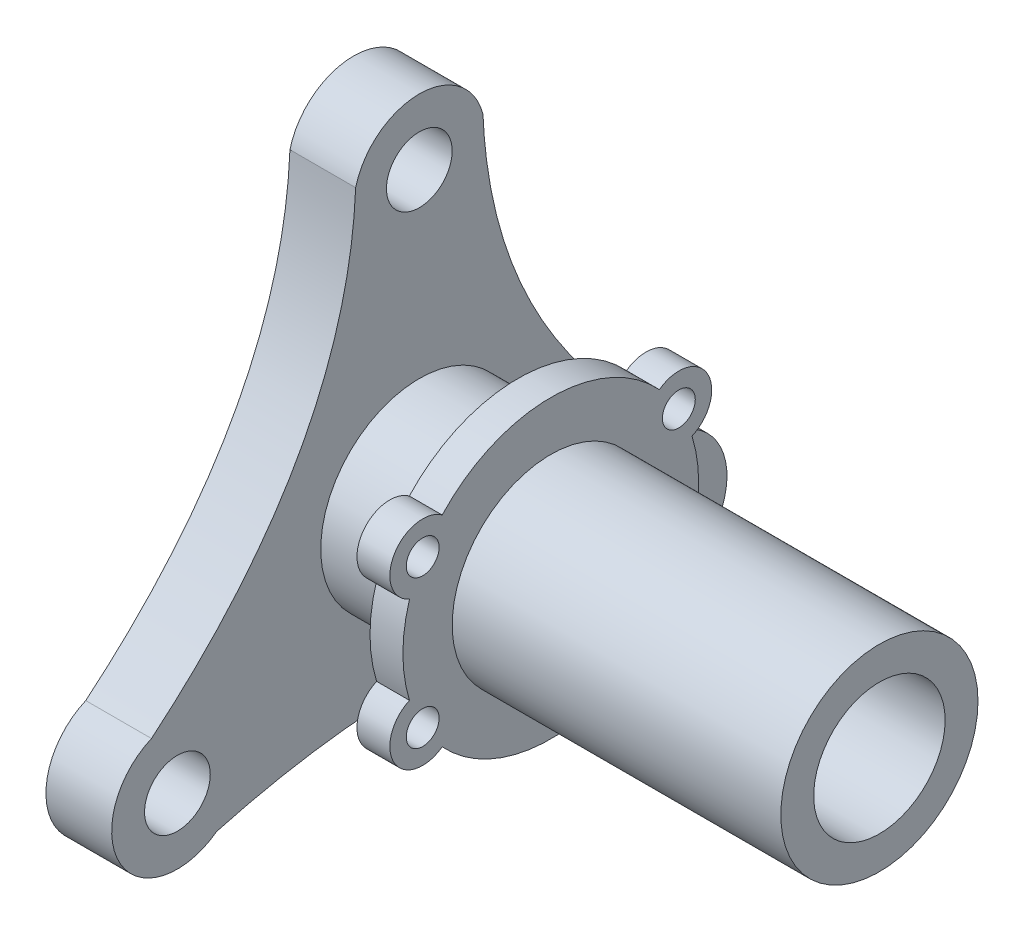
from build123d import *

# Parameters (mm, degrees)
SKETCH2_R           = 5
SKETCH2_R_2         = 10
BOSS_EXTRUDE2_DEPTH = 10
SKETCH3_R           = 15
SKETCH3_R_2         = 10
BOSS_EXTRUDE3_DEPTH = 20
SKETCH4_R           = 2.5
SKETCH4_R_2         = 15
BOSS_EXTRUDE5_DEPTH = 5
SKETCH5_R           = 15
SKETCH5_R_2         = 10
BOSS_EXTRUDE6_DEPTH = 50


with BuildPart() as part:
    # Sketch2 → Boss-Extrude2 (new body)
    with BuildSketch(Plane(origin=(0, 0, 0), x_dir=(0, 0, -1), z_dir=(1, 0, 0))):
        with BuildLine():
            ThreePointArc((9.684825363, 44.990814664), (8e-08, 52.5), (-9.684825323, 44.990814819))
            add(Edge.make_bspline(
                [(-40.752503599, -12.061652047), (-20.934905138, 4.420586079), (-10.579005904, 23.438067717), (-9.684825323, 44.990814819)],
                knots=[0, 0, 0, 0, 0.868352025, 0.868352025, 0.868352025, 0.868352025], degree=3))
            ThreePointArc((-40.752503599, -12.061652047), (-45.466333468, -26.2500004), (-30.821948144, -29.261876808))
            add(Edge.make_bspline(
                [(-30.821948144, -29.261876808), (1.426149217, -20.445917502), (30.821948237, -29.261876878)],
                knots=[0, 0, 0, 0.907199698, 0.907199698, 0.907199698], degree=2))
            ThreePointArc((30.821948237, -29.261876878), (45.466333568, -26.250000227), (40.752503338, -12.061651935))
            add(Edge.make_bspline(
                [(40.752503338, -12.061651935), (11.072313354, 12.162082971), (9.684825363, 44.990814664)],
                knots=[0, 0, 0, 1, 1, 1], degree=2))
        make_face()
        with Locations((0, 42.5)):
            Circle(SKETCH2_R, mode=Mode.SUBTRACT)
        with Locations((36.806079661, -21.25)):
            Circle(SKETCH2_R, mode=Mode.SUBTRACT)
        with Locations((-36.806079661, -21.25)):
            Circle(SKETCH2_R, mode=Mode.SUBTRACT)
        Circle(SKETCH2_R_2, mode=Mode.SUBTRACT)
    extrude(amount=BOSS_EXTRUDE2_DEPTH)

    # Sketch3 → Boss-Extrude3 (add)
    with BuildSketch(Plane(origin=(10, 0, 0), x_dir=(0, 0, -1), z_dir=(1, 0, 0))):
        Circle(SKETCH3_R)
        Circle(SKETCH3_R_2, mode=Mode.SUBTRACT)
    extrude(amount=BOSS_EXTRUDE3_DEPTH)

    # Sketch4 → Boss-Extrude5 (add)
    with BuildSketch(Plane(origin=(30, 0, 0), x_dir=(0, 0, -1), z_dir=(1, 0, 0))):
        with BuildLine():
            ThreePointArc((21.488966336, 6.668907393), (23.815698604, 13.75), (16.519926386, 15.275537051))
            ThreePointArc((16.519926386, 15.275537051), (0, 22.5), (-16.519926386, 15.275537051))
            ThreePointArc((-16.519926386, 15.275537051), (-23.815698604, 13.75), (-21.488966336, 6.668907393))
            ThreePointArc((-21.488966336, 6.668907393), (-22.5, 0), (-21.488966336, -6.668907393))
            ThreePointArc((-21.488966336, -6.668907393), (-23.815698604, -13.75), (-16.519926386, -15.275537051))
            ThreePointArc((-16.519926386, -15.275537051), (0, -22.5), (16.519926386, -15.275537051))
            ThreePointArc((16.519926386, -15.275537051), (23.815698604, -13.75), (21.488966336, -6.668907393))
            ThreePointArc((21.488966336, -6.668907393), (22.5, 0), (21.488966336, 6.668907393))
        make_face()
        with Locations((19.485571585, 11.25)):
            Circle(SKETCH4_R, mode=Mode.SUBTRACT)
        with Locations((19.485571585, -11.25)):
            Circle(SKETCH4_R, mode=Mode.SUBTRACT)
        with Locations((-19.485571585, -11.25)):
            Circle(SKETCH4_R, mode=Mode.SUBTRACT)
        with Locations((-19.485571585, 11.25)):
            Circle(SKETCH4_R, mode=Mode.SUBTRACT)
        Circle(SKETCH4_R_2, mode=Mode.SUBTRACT)
    extrude(amount=-BOSS_EXTRUDE5_DEPTH)

    # Sketch5 → Boss-Extrude6 (add)
    with BuildSketch(Plane(origin=(30, 0, 0), x_dir=(0, 0, -1), z_dir=(1, 0, 0))):
        Circle(SKETCH5_R)
        Circle(SKETCH5_R_2, mode=Mode.SUBTRACT)
    extrude(amount=BOSS_EXTRUDE6_DEPTH)


solid = part.part
